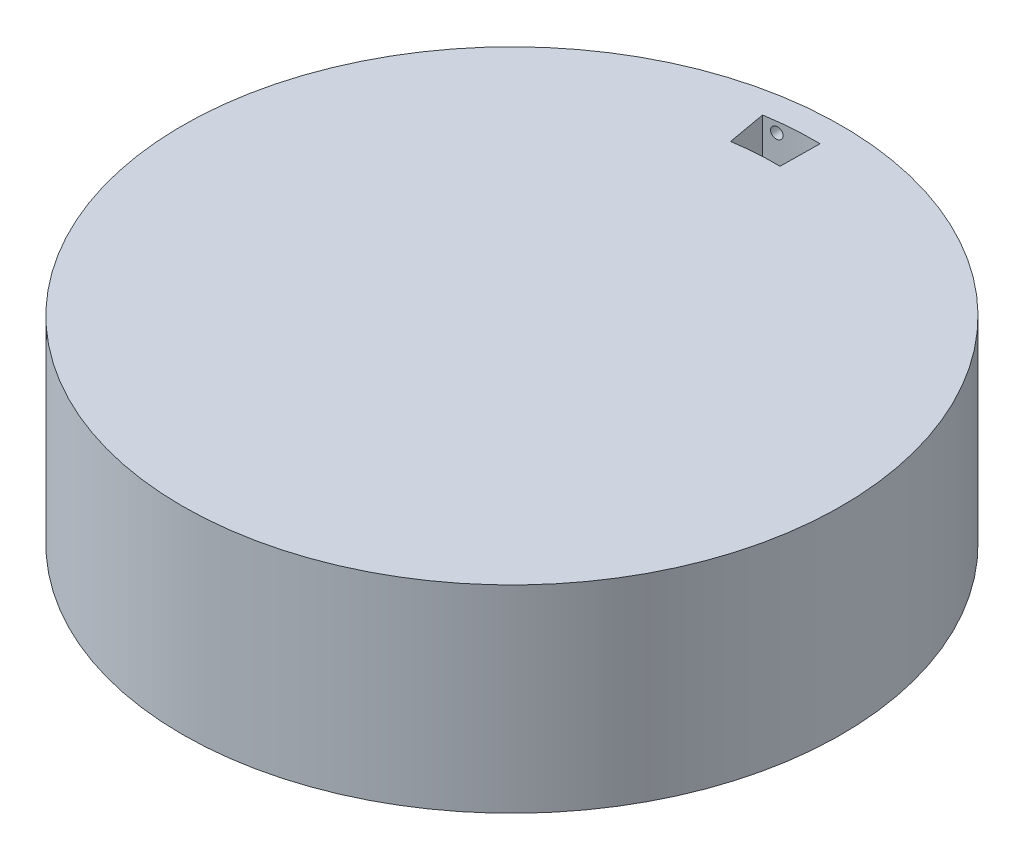
from build123d import *

# Parameters (mm, degrees)
SKETCH1_R               = 31.75
BOSS_EXTRUDE1_DEPTH     = 19.05
CUT_EXTRUDE1_DEPTH      = 5.08
SKETCH4_R               = 0.539725026
CUT_EXTRUDE2_DEPTH      = 9.62045401
CUT_EXTRUDE2_DEPTH_BACK = 1.524


with BuildPart() as part:
    # Sketch1 → Boss-Extrude1 (new body)
    with BuildSketch(Plane(origin=(0, 0, 0), x_dir=(1, 0, 0), z_dir=(0, 1, 0))):
        Circle(SKETCH1_R)
    extrude(amount=BOSS_EXTRUDE1_DEPTH)

    # Sketch2 → Cut-Extrude1 (cut)
    with BuildSketch(Plane(origin=(0, 19.05, 0), x_dir=(1, 0, 0), z_dir=(0, 1, 0))):
        with BuildLine():
            Line((0.431861346, 25.396328392), (0.481566937, 29.206030084))
            ThreePointArc((0.481566937, 29.206030084), (-2.110193645, 29.133677811), (-4.685328245, 28.831784531))
            Line((-4.685328245, 28.831784531), (-4.021364533, 25.079645677))
            ThreePointArc((-4.021364533, 25.079645677), (-1.801722861, 25.336017736), (0.431861346, 25.396328392))
        make_face()
    extrude(amount=-CUT_EXTRUDE1_DEPTH, mode=Mode.SUBTRACT)

    # Sketch4 → Cut-Extrude2 (cut, two sides)
    with BuildSketch(Plane(origin=(-1.794751593, 0, -25.237987034), x_dir=(-0.997481013, 0, 0.070933971), z_dir=(-0.070933971, 0, -0.997481013))) as cut_extrude2_sk:
        with Locations((1.415895648, 18.077123557)):
            Circle(SKETCH4_R)
    extrude(amount=CUT_EXTRUDE2_DEPTH, mode=Mode.SUBTRACT)
    extrude(cut_extrude2_sk.sketch, amount=-CUT_EXTRUDE2_DEPTH_BACK, mode=Mode.SUBTRACT)


solid = part.part
